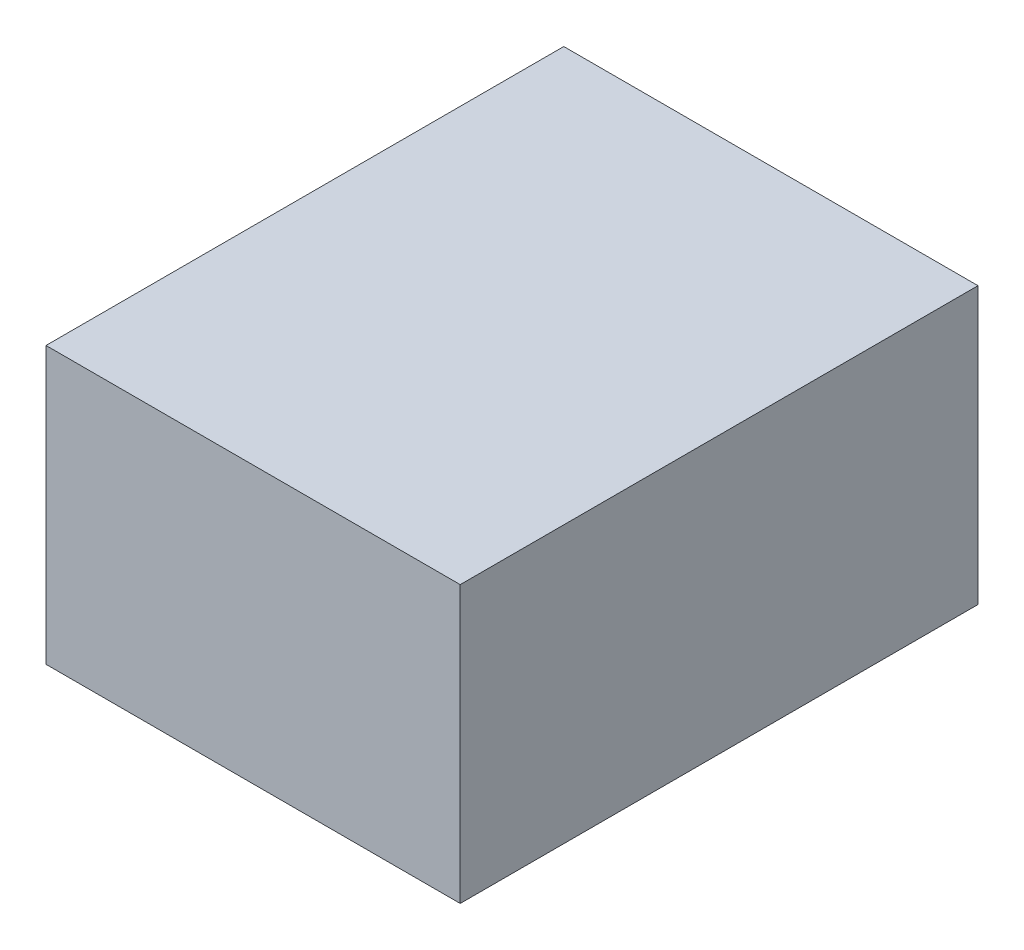
from build123d import *

# Parameters (mm, degrees)
SKETCH1_W           = 304.8
SKETCH1_H           = 203.2
BOSS_EXTRUDE1_DEPTH = 190.5


with BuildPart() as part:
    # Sketch1 → Boss-Extrude1 (new, symmetric)
    with BuildSketch(Plane.XY):
        with Locations((152.4, 101.6)):
            Rectangle(SKETCH1_W, SKETCH1_H)
    extrude(amount=BOSS_EXTRUDE1_DEPTH, both=True)


solid = part.part
